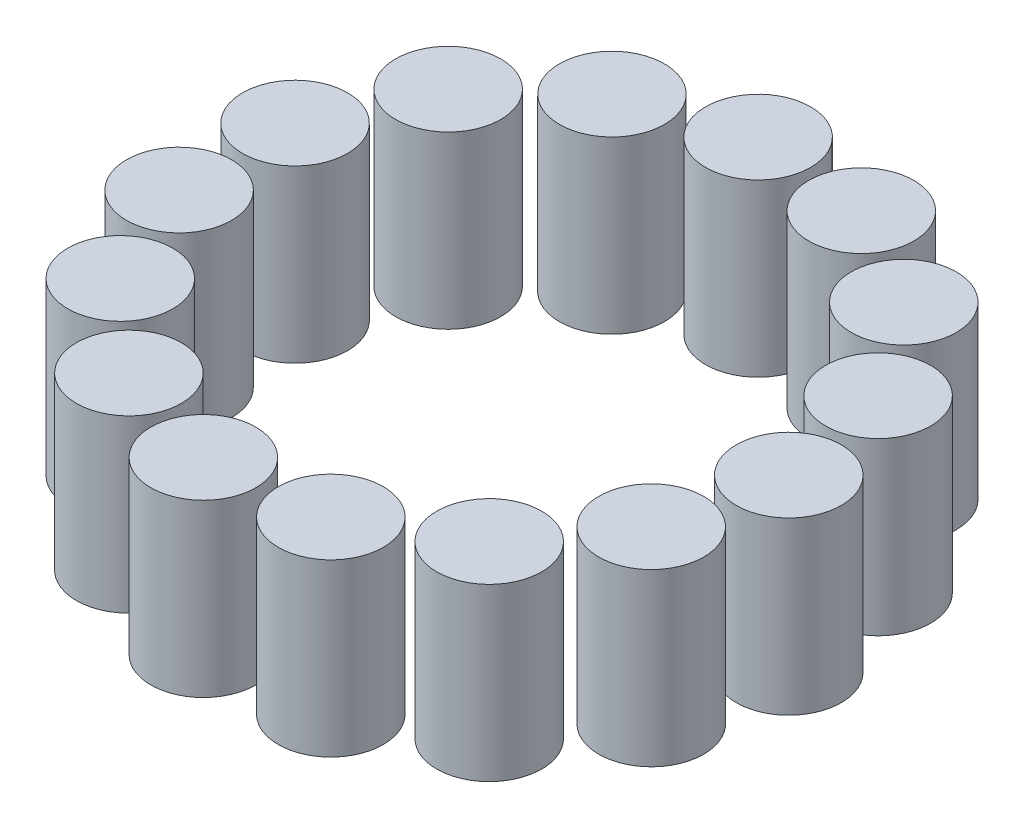
from build123d import *

# Parameters (mm, degrees)
SKETCH1_R           = 3.075
BOSS_EXTRUDE1_DEPTH = 10
CIRPATTERN1_COUNT   = 15


with BuildPart() as part:
    # Sketch1 → Boss-Extrude1 (new body)
    with BuildSketch(Plane(origin=(0, 0, 0), x_dir=(1, 0, 0), z_dir=(0, 1, 0))):
        with Locations((16.325, 0)):
            Circle(SKETCH1_R)
    extrude(amount=BOSS_EXTRUDE1_DEPTH)


with BuildPart() as cirpattern1_1:
    # CirPattern1: pattern copy
    add(part.part.rotate(Axis((0, 0, 0), (0, 1, 0)), 1 * 360 / CIRPATTERN1_COUNT))


with BuildPart() as cirpattern1_2:
    # CirPattern1: pattern copy
    add(part.part.rotate(Axis((0, 0, 0), (0, 1, 0)), 2 * 360 / CIRPATTERN1_COUNT))


with BuildPart() as cirpattern1_3:
    # CirPattern1: pattern copy
    add(part.part.rotate(Axis((0, 0, 0), (0, 1, 0)), 3 * 360 / CIRPATTERN1_COUNT))


with BuildPart() as cirpattern1_4:
    # CirPattern1: pattern copy
    add(part.part.rotate(Axis((0, 0, 0), (0, 1, 0)), 4 * 360 / CIRPATTERN1_COUNT))


with BuildPart() as cirpattern1_5:
    # CirPattern1: pattern copy
    add(part.part.rotate(Axis((0, 0, 0), (0, 1, 0)), 5 * 360 / CIRPATTERN1_COUNT))


with BuildPart() as cirpattern1_6:
    # CirPattern1: pattern copy
    add(part.part.rotate(Axis((0, 0, 0), (0, 1, 0)), 6 * 360 / CIRPATTERN1_COUNT))


with BuildPart() as cirpattern1_7:
    # CirPattern1: pattern copy
    add(part.part.rotate(Axis((0, 0, 0), (0, 1, 0)), 7 * 360 / CIRPATTERN1_COUNT))


with BuildPart() as cirpattern1_8:
    # CirPattern1: pattern copy
    add(part.part.rotate(Axis((0, 0, 0), (0, 1, 0)), 8 * 360 / CIRPATTERN1_COUNT))


with BuildPart() as cirpattern1_9:
    # CirPattern1: pattern copy
    add(part.part.rotate(Axis((0, 0, 0), (0, 1, 0)), 9 * 360 / CIRPATTERN1_COUNT))


with BuildPart() as cirpattern1_10:
    # CirPattern1: pattern copy
    add(part.part.rotate(Axis((0, 0, 0), (0, 1, 0)), 10 * 360 / CIRPATTERN1_COUNT))


with BuildPart() as cirpattern1_11:
    # CirPattern1: pattern copy
    add(part.part.rotate(Axis((0, 0, 0), (0, 1, 0)), 11 * 360 / CIRPATTERN1_COUNT))


with BuildPart() as cirpattern1_12:
    # CirPattern1: pattern copy
    add(part.part.rotate(Axis((0, 0, 0), (0, 1, 0)), 12 * 360 / CIRPATTERN1_COUNT))


with BuildPart() as cirpattern1_13:
    # CirPattern1: pattern copy
    add(part.part.rotate(Axis((0, 0, 0), (0, 1, 0)), 13 * 360 / CIRPATTERN1_COUNT))


with BuildPart() as cirpattern1_14:
    # CirPattern1: pattern copy
    add(part.part.rotate(Axis((0, 0, 0), (0, 1, 0)), 14 * 360 / CIRPATTERN1_COUNT))


solid = Compound([part.part, cirpattern1_1.part, cirpattern1_2.part, cirpattern1_3.part, cirpattern1_4.part, cirpattern1_5.part, cirpattern1_6.part, cirpattern1_7.part, cirpattern1_8.part, cirpattern1_9.part, cirpattern1_10.part, cirpattern1_11.part, cirpattern1_12.part, cirpattern1_13.part, cirpattern1_14.part])
